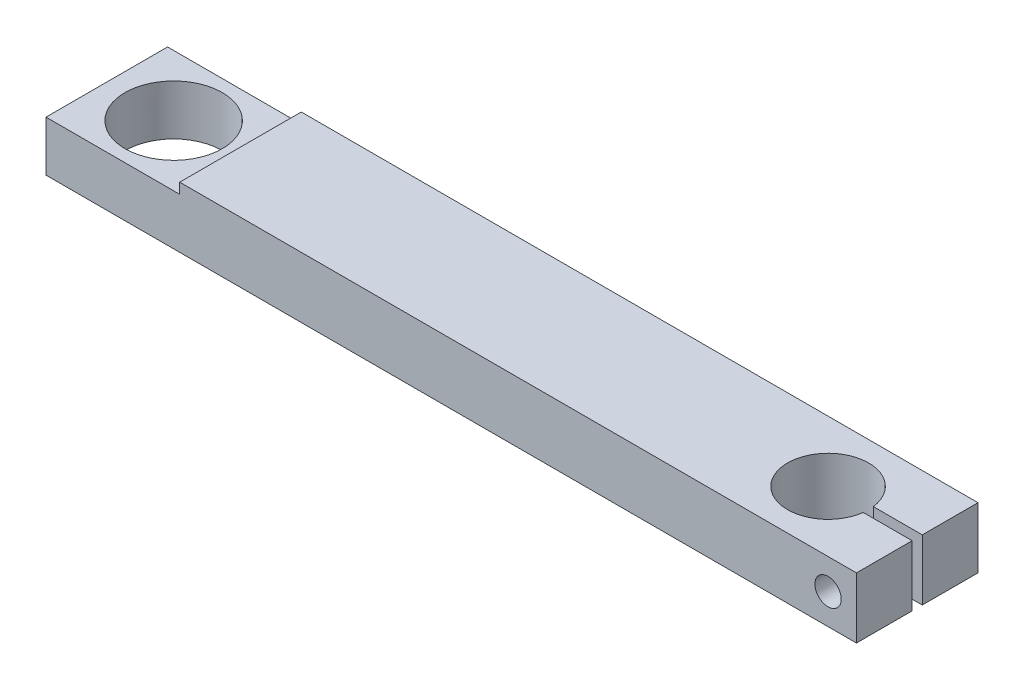
from build123d import *

# Parameters (mm, degrees)
SKETCH1_R           = 12
BOSS_EXTRUDE1_DEPTH = 15
SKETCH2_R           = 5.25
CUT_EXTRUDE1_DEPTH  = 7
SKETCH3_R           = 3.25
CUT_EXTRUDE2_DEPTH  = 24
SKETCH4_W           = 33
SKETCH4_H           = 2.6
CUT_EXTRUDE3_DEPTH  = 31


with BuildPart() as part:
    # Sketch1 → Boss-Extrude1 (new body)
    with BuildSketch(Plane(origin=(0, 0, 0), x_dir=(1, 0, 0), z_dir=(0, 1, 0))):
        with BuildLine():
            ThreePointArc((87.921567416, -1.25), (68, 0), (87.921567416, 1.25))
            Line((87.921567416, 1.25), (100, 1.25))
            Line((100, 1.25), (100, 15))
            Line((100, 15), (-100, 15))
            Line((-100, 15), (-100, -15))
            Line((-100, -15), (100, -15))
            Line((100, -15), (100, -1.25))
            Line((100, -1.25), (87.921567416, -1.25))
        make_face()
        with Locations((-83.5, 0)):
            Circle(SKETCH1_R, mode=Mode.SUBTRACT)
    extrude(amount=BOSS_EXTRUDE1_DEPTH)

    # Sketch2 → Cut-Extrude1 (cut)
    with BuildSketch(Plane(origin=(0, 0, -15), x_dir=(-1, 0, 0), z_dir=(0, 0, -1))):
        with Locations((-93, 7.5)):
            Circle(SKETCH2_R)
    extrude(amount=-CUT_EXTRUDE1_DEPTH, mode=Mode.SUBTRACT)

    # Sketch3 → Cut-Extrude2 (cut, through all)
    with BuildSketch(Plane(origin=(0, 0, -8), x_dir=(-1, 0, 0), z_dir=(0, 0, -1))):
        with Locations((-93, 7.5)):
            Circle(SKETCH3_R)
    extrude(amount=-CUT_EXTRUDE2_DEPTH, mode=Mode.SUBTRACT)

    # Sketch4 → Cut-Extrude3 (cut, through all)
    with BuildSketch(Plane(origin=(0, 0, -15), x_dir=(-1, 0, 0), z_dir=(0, 0, -1))):
        with Locations((83.5, 13.7)):
            Rectangle(SKETCH4_W, SKETCH4_H)
    extrude(amount=-CUT_EXTRUDE3_DEPTH, mode=Mode.SUBTRACT)


solid = part.part
